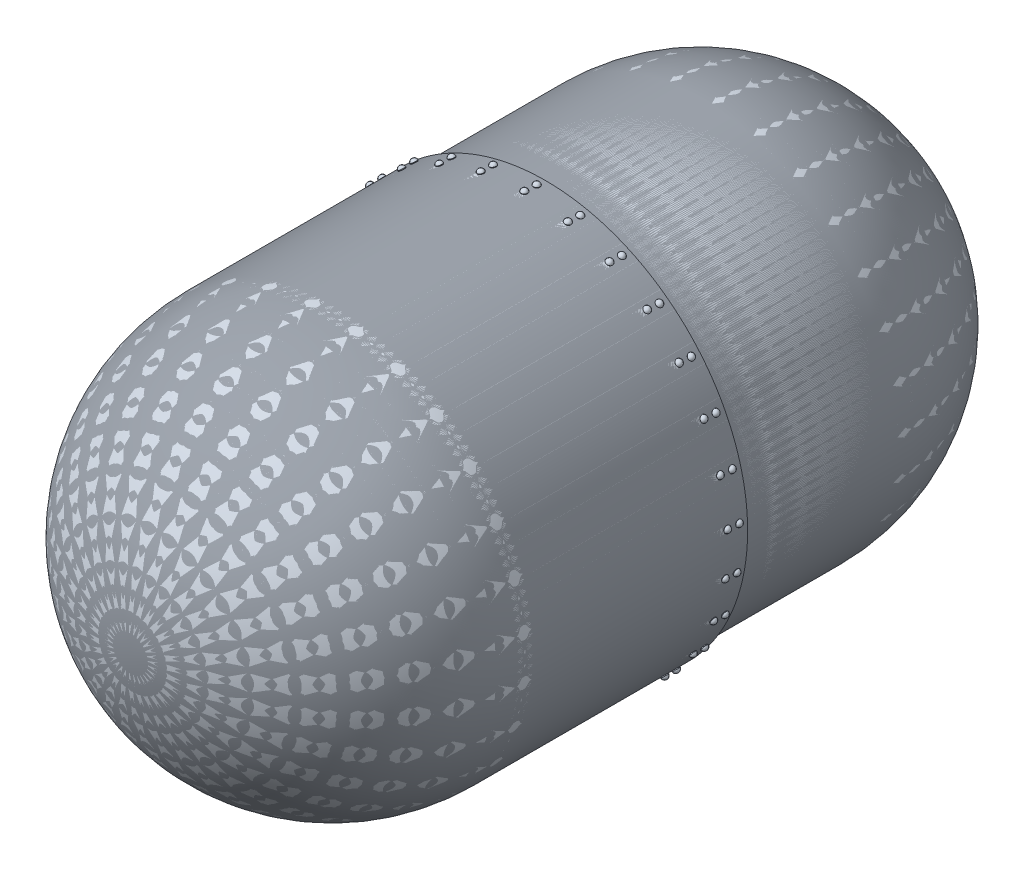
from build123d import *

# Parameters (mm, degrees)
SKETCH1_R                = 1200
SKETCH1_R_2              = 1165
BOSS_EXTRUDE1_DEPTH      = 1126
SKETCH2_R                = 1235
SKETCH2_R_2              = 1200
BOSS_EXTRUDE2_DEPTH      = 1126
BOSS_EXTRUDE2_DEPTH_BACK = 180
CIRPATTERN1_COUNT        = 29
CIRPATTERN2_COUNT        = 29


with BuildPart() as part:
    # Sketch1 → Boss-Extrude1 (new body)
    with BuildSketch(Plane.XY):
        Circle(SKETCH1_R)
        Circle(SKETCH1_R_2, mode=Mode.SUBTRACT)
    extrude(amount=BOSS_EXTRUDE1_DEPTH)

    # Sketch2 → Boss-Extrude2 (add, two sides)
    with BuildSketch(Plane.XY.offset(1126)) as boss_extrude2_sk:
        Circle(SKETCH2_R)
        Circle(SKETCH2_R_2, mode=Mode.SUBTRACT)
    extrude(amount=BOSS_EXTRUDE2_DEPTH)
    extrude(boss_extrude2_sk.sketch, amount=-BOSS_EXTRUDE2_DEPTH_BACK)

    # Sketch9 → Revolve3 (revolve)
    with BuildSketch(Plane(origin=(0, 0, 0), x_dir=(1, 0, 0), z_dir=(0, 1, 0))):
        with BuildLine():
            Line((0, 0), (1200, 0))
            ThreePointArc((1200, 0), (848.528137424, 848.528137424), (0, 1200))
            Line((0, 1200), (0, 0))
        make_face()
    revolve(axis=Axis((0, 0, -1200), (0, 0, 1)))

    # Sketch10 → Revolve4 (revolve)
    with BuildSketch(Plane(origin=(0, 0, 0), x_dir=(1, 0, 0), z_dir=(0, 1, 0))):
        with BuildLine():
            Line((0, -2252), (1235, -2252))
            ThreePointArc((1235, -2252), (873.276874765, -3125.276874765), (0, -3487))
            Line((0, -3487), (0, -2252))
        make_face()
    revolve(axis=Axis((0, 0, 2252), (0, 0, 1)))

    # Sketch11 → Revolve5 (revolve)
    with BuildSketch(Plane(origin=(0, 0, 1072), x_dir=(-1, 0, 0), z_dir=(0, 0, -1))):
        Polygon((-261.966155588, 1206.762086464), (-244.375851886, 1210.58062227), (-242.791544194, 1215.529356364), (-262.920789539, 1211.159662389), align=None)
    revolve(axis=Axis((262.920789539, 1211.159662389, 1072), (-0.212140878, -0.977239095, 0)))

    # Sketch12 → Revolve6 (revolve)
    with BuildSketch(Plane(origin=(0, 0, 1072), x_dir=(-1, 0, 0), z_dir=(0, 0, -1))):
        with BuildLine():
            Line((-266.593012276, 1228.075966566), (-262.920789539, 1211.159662389))
            Line((-262.920789539, 1211.159662389), (-242.791544194, 1215.529356364))
            ThreePointArc((-242.791544194, 1215.529356364), (-252.406305087, 1226.139252468), (-266.593012276, 1228.075966566))
        make_face()
    revolve(axis=Axis((266.593012276, 1228.075966566, 1072), (-0.212140878, -0.977239095, 0)))


with BuildPart() as body_2:
    # Sketch7 → Revolve1 (revolve)
    with BuildSketch(Plane(origin=(0, 0, 1000), x_dir=(-1, 0, 0), z_dir=(0, 0, -1))):
        Polygon((0, 1235), (18, 1235), (20.598076211, 1239.5), (0, 1239.5), align=None)
    revolve(axis=Axis((0, 0, 1000), (0, 1, 0)))

    # Sketch8 → Revolve2 (revolve)
    with BuildSketch(Plane(origin=(0, 0, 1000), x_dir=(-1, 0, 0), z_dir=(0, 0, -1))):
        with BuildLine():
            Line((0, 1256.810302332), (0, 1239.5))
            Line((0, 1239.5), (20.598076211, 1239.5))
            ThreePointArc((20.598076211, 1239.5), (13.452948658, 1251.90808908), (0, 1256.810302332))
        make_face()
    revolve(axis=Axis((0, 1256.810302332, 1000), (0, -1, 0)))


with BuildPart() as cirpattern1_1:
    # CirPattern1: pattern copy
    add(body_2.part.rotate(Axis((0, 0, 946), (0, 0, 1)), 1 * 360 / CIRPATTERN1_COUNT))


with BuildPart() as cirpattern1_2:
    # CirPattern1: pattern copy
    add(body_2.part.rotate(Axis((0, 0, 946), (0, 0, 1)), 2 * 360 / CIRPATTERN1_COUNT))


with BuildPart() as cirpattern1_3:
    # CirPattern1: pattern copy
    add(body_2.part.rotate(Axis((0, 0, 946), (0, 0, 1)), 3 * 360 / CIRPATTERN1_COUNT))


with BuildPart() as cirpattern1_4:
    # CirPattern1: pattern copy
    add(body_2.part.rotate(Axis((0, 0, 946), (0, 0, 1)), 4 * 360 / CIRPATTERN1_COUNT))


with BuildPart() as cirpattern1_5:
    # CirPattern1: pattern copy
    add(body_2.part.rotate(Axis((0, 0, 946), (0, 0, 1)), 5 * 360 / CIRPATTERN1_COUNT))


with BuildPart() as cirpattern1_6:
    # CirPattern1: pattern copy
    add(body_2.part.rotate(Axis((0, 0, 946), (0, 0, 1)), 6 * 360 / CIRPATTERN1_COUNT))


with BuildPart() as cirpattern1_7:
    # CirPattern1: pattern copy
    add(body_2.part.rotate(Axis((0, 0, 946), (0, 0, 1)), 7 * 360 / CIRPATTERN1_COUNT))


with BuildPart() as cirpattern1_8:
    # CirPattern1: pattern copy
    add(body_2.part.rotate(Axis((0, 0, 946), (0, 0, 1)), 8 * 360 / CIRPATTERN1_COUNT))


with BuildPart() as cirpattern1_9:
    # CirPattern1: pattern copy
    add(body_2.part.rotate(Axis((0, 0, 946), (0, 0, 1)), 9 * 360 / CIRPATTERN1_COUNT))


with BuildPart() as cirpattern1_10:
    # CirPattern1: pattern copy
    add(body_2.part.rotate(Axis((0, 0, 946), (0, 0, 1)), 10 * 360 / CIRPATTERN1_COUNT))


with BuildPart() as cirpattern1_11:
    # CirPattern1: pattern copy
    add(body_2.part.rotate(Axis((0, 0, 946), (0, 0, 1)), 11 * 360 / CIRPATTERN1_COUNT))


with BuildPart() as cirpattern1_12:
    # CirPattern1: pattern copy
    add(body_2.part.rotate(Axis((0, 0, 946), (0, 0, 1)), 12 * 360 / CIRPATTERN1_COUNT))


with BuildPart() as cirpattern1_13:
    # CirPattern1: pattern copy
    add(body_2.part.rotate(Axis((0, 0, 946), (0, 0, 1)), 13 * 360 / CIRPATTERN1_COUNT))


with BuildPart() as cirpattern1_14:
    # CirPattern1: pattern copy
    add(body_2.part.rotate(Axis((0, 0, 946), (0, 0, 1)), 14 * 360 / CIRPATTERN1_COUNT))


with BuildPart() as cirpattern1_15:
    # CirPattern1: pattern copy
    add(body_2.part.rotate(Axis((0, 0, 946), (0, 0, 1)), 15 * 360 / CIRPATTERN1_COUNT))


with BuildPart() as cirpattern1_16:
    # CirPattern1: pattern copy
    add(body_2.part.rotate(Axis((0, 0, 946), (0, 0, 1)), 16 * 360 / CIRPATTERN1_COUNT))


with BuildPart() as cirpattern1_17:
    # CirPattern1: pattern copy
    add(body_2.part.rotate(Axis((0, 0, 946), (0, 0, 1)), 17 * 360 / CIRPATTERN1_COUNT))


with BuildPart() as cirpattern1_18:
    # CirPattern1: pattern copy
    add(body_2.part.rotate(Axis((0, 0, 946), (0, 0, 1)), 18 * 360 / CIRPATTERN1_COUNT))


with BuildPart() as cirpattern1_19:
    # CirPattern1: pattern copy
    add(body_2.part.rotate(Axis((0, 0, 946), (0, 0, 1)), 19 * 360 / CIRPATTERN1_COUNT))


with BuildPart() as cirpattern1_20:
    # CirPattern1: pattern copy
    add(body_2.part.rotate(Axis((0, 0, 946), (0, 0, 1)), 20 * 360 / CIRPATTERN1_COUNT))


with BuildPart() as cirpattern1_21:
    # CirPattern1: pattern copy
    add(body_2.part.rotate(Axis((0, 0, 946), (0, 0, 1)), 21 * 360 / CIRPATTERN1_COUNT))


with BuildPart() as cirpattern1_22:
    # CirPattern1: pattern copy
    add(body_2.part.rotate(Axis((0, 0, 946), (0, 0, 1)), 22 * 360 / CIRPATTERN1_COUNT))


with BuildPart() as cirpattern1_23:
    # CirPattern1: pattern copy
    add(body_2.part.rotate(Axis((0, 0, 946), (0, 0, 1)), 23 * 360 / CIRPATTERN1_COUNT))


with BuildPart() as cirpattern1_24:
    # CirPattern1: pattern copy
    add(body_2.part.rotate(Axis((0, 0, 946), (0, 0, 1)), 24 * 360 / CIRPATTERN1_COUNT))


with BuildPart() as cirpattern1_25:
    # CirPattern1: pattern copy
    add(body_2.part.rotate(Axis((0, 0, 946), (0, 0, 1)), 25 * 360 / CIRPATTERN1_COUNT))


with BuildPart() as cirpattern1_26:
    # CirPattern1: pattern copy
    add(body_2.part.rotate(Axis((0, 0, 946), (0, 0, 1)), 26 * 360 / CIRPATTERN1_COUNT))


with BuildPart() as cirpattern1_27:
    # CirPattern1: pattern copy
    add(body_2.part.rotate(Axis((0, 0, 946), (0, 0, 1)), 27 * 360 / CIRPATTERN1_COUNT))


with BuildPart() as cirpattern1_28:
    # CirPattern1: pattern copy
    add(body_2.part.rotate(Axis((0, 0, 946), (0, 0, 1)), 28 * 360 / CIRPATTERN1_COUNT))


with BuildPart() as cirpattern2_1:
    # CirPattern2: pattern copy
    add(part.part.rotate(Axis((0, 0, 946), (0, 0, 1)), 1 * 360 / CIRPATTERN2_COUNT))


with BuildPart() as cirpattern2_2:
    # CirPattern2: pattern copy
    add(part.part.rotate(Axis((0, 0, 946), (0, 0, 1)), 2 * 360 / CIRPATTERN2_COUNT))


with BuildPart() as cirpattern2_3:
    # CirPattern2: pattern copy
    add(part.part.rotate(Axis((0, 0, 946), (0, 0, 1)), 3 * 360 / CIRPATTERN2_COUNT))


with BuildPart() as cirpattern2_4:
    # CirPattern2: pattern copy
    add(part.part.rotate(Axis((0, 0, 946), (0, 0, 1)), 4 * 360 / CIRPATTERN2_COUNT))


with BuildPart() as cirpattern2_5:
    # CirPattern2: pattern copy
    add(part.part.rotate(Axis((0, 0, 946), (0, 0, 1)), 5 * 360 / CIRPATTERN2_COUNT))


with BuildPart() as cirpattern2_6:
    # CirPattern2: pattern copy
    add(part.part.rotate(Axis((0, 0, 946), (0, 0, 1)), 6 * 360 / CIRPATTERN2_COUNT))


with BuildPart() as cirpattern2_7:
    # CirPattern2: pattern copy
    add(part.part.rotate(Axis((0, 0, 946), (0, 0, 1)), 7 * 360 / CIRPATTERN2_COUNT))


with BuildPart() as cirpattern2_8:
    # CirPattern2: pattern copy
    add(part.part.rotate(Axis((0, 0, 946), (0, 0, 1)), 8 * 360 / CIRPATTERN2_COUNT))


with BuildPart() as cirpattern2_9:
    # CirPattern2: pattern copy
    add(part.part.rotate(Axis((0, 0, 946), (0, 0, 1)), 9 * 360 / CIRPATTERN2_COUNT))


with BuildPart() as cirpattern2_10:
    # CirPattern2: pattern copy
    add(part.part.rotate(Axis((0, 0, 946), (0, 0, 1)), 10 * 360 / CIRPATTERN2_COUNT))


with BuildPart() as cirpattern2_11:
    # CirPattern2: pattern copy
    add(part.part.rotate(Axis((0, 0, 946), (0, 0, 1)), 11 * 360 / CIRPATTERN2_COUNT))


with BuildPart() as cirpattern2_12:
    # CirPattern2: pattern copy
    add(part.part.rotate(Axis((0, 0, 946), (0, 0, 1)), 12 * 360 / CIRPATTERN2_COUNT))


with BuildPart() as cirpattern2_13:
    # CirPattern2: pattern copy
    add(part.part.rotate(Axis((0, 0, 946), (0, 0, 1)), 13 * 360 / CIRPATTERN2_COUNT))


with BuildPart() as cirpattern2_14:
    # CirPattern2: pattern copy
    add(part.part.rotate(Axis((0, 0, 946), (0, 0, 1)), 14 * 360 / CIRPATTERN2_COUNT))


with BuildPart() as cirpattern2_15:
    # CirPattern2: pattern copy
    add(part.part.rotate(Axis((0, 0, 946), (0, 0, 1)), 15 * 360 / CIRPATTERN2_COUNT))


with BuildPart() as cirpattern2_16:
    # CirPattern2: pattern copy
    add(part.part.rotate(Axis((0, 0, 946), (0, 0, 1)), 16 * 360 / CIRPATTERN2_COUNT))


with BuildPart() as cirpattern2_17:
    # CirPattern2: pattern copy
    add(part.part.rotate(Axis((0, 0, 946), (0, 0, 1)), 17 * 360 / CIRPATTERN2_COUNT))


with BuildPart() as cirpattern2_18:
    # CirPattern2: pattern copy
    add(part.part.rotate(Axis((0, 0, 946), (0, 0, 1)), 18 * 360 / CIRPATTERN2_COUNT))


with BuildPart() as cirpattern2_19:
    # CirPattern2: pattern copy
    add(part.part.rotate(Axis((0, 0, 946), (0, 0, 1)), 19 * 360 / CIRPATTERN2_COUNT))


with BuildPart() as cirpattern2_20:
    # CirPattern2: pattern copy
    add(part.part.rotate(Axis((0, 0, 946), (0, 0, 1)), 20 * 360 / CIRPATTERN2_COUNT))


with BuildPart() as cirpattern2_21:
    # CirPattern2: pattern copy
    add(part.part.rotate(Axis((0, 0, 946), (0, 0, 1)), 21 * 360 / CIRPATTERN2_COUNT))


with BuildPart() as cirpattern2_22:
    # CirPattern2: pattern copy
    add(part.part.rotate(Axis((0, 0, 946), (0, 0, 1)), 22 * 360 / CIRPATTERN2_COUNT))


with BuildPart() as cirpattern2_23:
    # CirPattern2: pattern copy
    add(part.part.rotate(Axis((0, 0, 946), (0, 0, 1)), 23 * 360 / CIRPATTERN2_COUNT))


with BuildPart() as cirpattern2_24:
    # CirPattern2: pattern copy
    add(part.part.rotate(Axis((0, 0, 946), (0, 0, 1)), 24 * 360 / CIRPATTERN2_COUNT))


with BuildPart() as cirpattern2_25:
    # CirPattern2: pattern copy
    add(part.part.rotate(Axis((0, 0, 946), (0, 0, 1)), 25 * 360 / CIRPATTERN2_COUNT))


with BuildPart() as cirpattern2_26:
    # CirPattern2: pattern copy
    add(part.part.rotate(Axis((0, 0, 946), (0, 0, 1)), 26 * 360 / CIRPATTERN2_COUNT))


with BuildPart() as cirpattern2_27:
    # CirPattern2: pattern copy
    add(part.part.rotate(Axis((0, 0, 946), (0, 0, 1)), 27 * 360 / CIRPATTERN2_COUNT))


with BuildPart() as cirpattern2_28:
    # CirPattern2: pattern copy
    add(part.part.rotate(Axis((0, 0, 946), (0, 0, 1)), 28 * 360 / CIRPATTERN2_COUNT))


solid = Compound([part.part, body_2.part, cirpattern1_1.part, cirpattern1_2.part, cirpattern1_3.part, cirpattern1_4.part, cirpattern1_5.part, cirpattern1_6.part, cirpattern1_7.part, cirpattern1_8.part, cirpattern1_9.part, cirpattern1_10.part, cirpattern1_11.part, cirpattern1_12.part, cirpattern1_13.part, cirpattern1_14.part, cirpattern1_15.part, cirpattern1_16.part, cirpattern1_17.part, cirpattern1_18.part, cirpattern1_19.part, cirpattern1_20.part, cirpattern1_21.part, cirpattern1_22.part, cirpattern1_23.part, cirpattern1_24.part, cirpattern1_25.part, cirpattern1_26.part, cirpattern1_27.part, cirpattern1_28.part, cirpattern2_1.part, cirpattern2_2.part, cirpattern2_3.part, cirpattern2_4.part, cirpattern2_5.part, cirpattern2_6.part, cirpattern2_7.part, cirpattern2_8.part, cirpattern2_9.part, cirpattern2_10.part, cirpattern2_11.part, cirpattern2_12.part, cirpattern2_13.part, cirpattern2_14.part, cirpattern2_15.part, cirpattern2_16.part, cirpattern2_17.part, cirpattern2_18.part, cirpattern2_19.part, cirpattern2_20.part, cirpattern2_21.part, cirpattern2_22.part, cirpattern2_23.part, cirpattern2_24.part, cirpattern2_25.part, cirpattern2_26.part, cirpattern2_27.part, cirpattern2_28.part])
